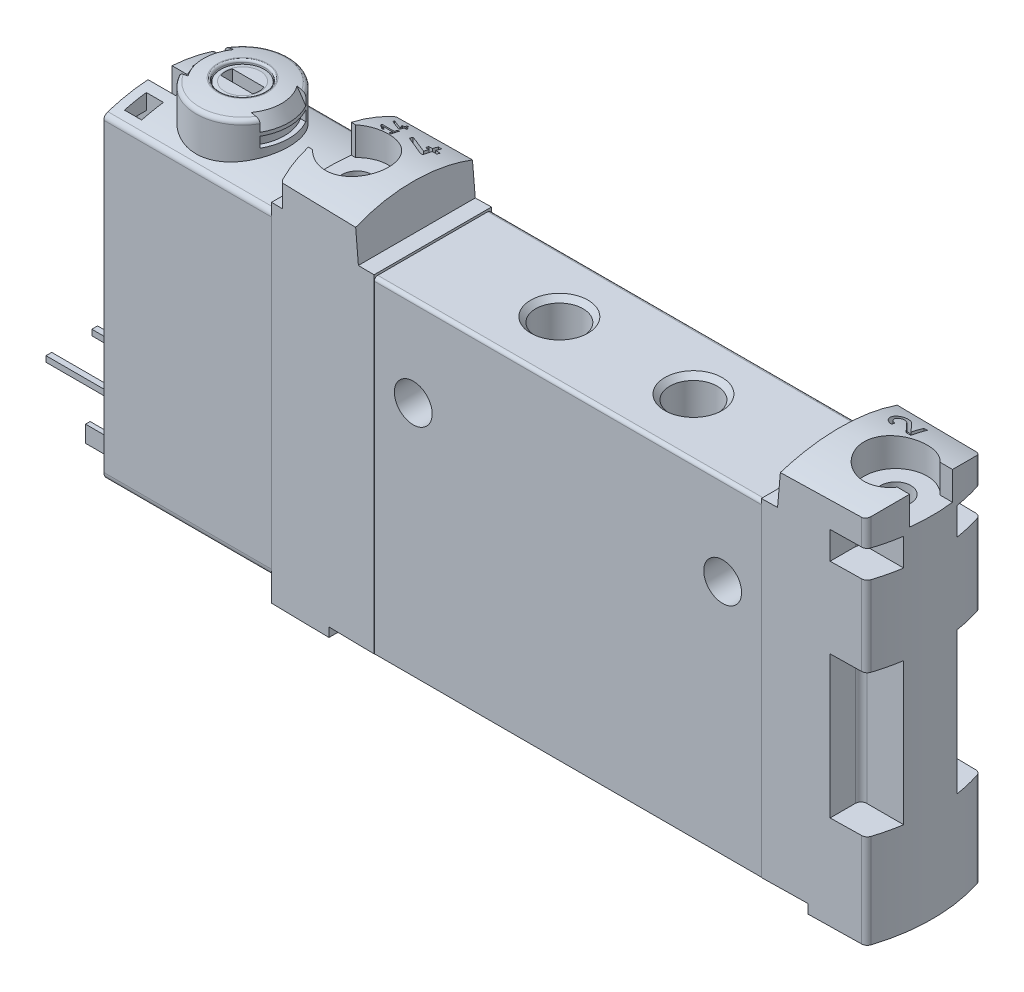
from build123d import *

# Parameters (mm, degrees)
BOSS_EXTRUDE1_DEPTH      = 16.9
BOSS_EXTRUDE1_DEPTH_BACK = 16.9
CUT_EXTRUDE1_DEPTH       = 6
CUT_EXTRUDE1_DEPTH_BACK  = 6
SKETCH2_R                = 1.65
CUT_EXTRUDE2_DEPTH       = 6
CUT_EXTRUDE2_DEPTH_BACK  = 6
SKETCH3_R                = 1.65
HOLE1_D                  = 4.134
HOLE1_DEPTH              = 13.5
HOLE1_CSINK_D            = 5
HOLE1_CSINK_ANGLE        = 90
HOLE2_D                  = 4.134
HOLE2_DEPTH              = 18.8
HOLE2_CSINK_D            = 5
HOLE2_CSINK_ANGLE        = 90
HOLE2_TIP                = 1.193383006
HOLE3_D                  = 4.134
HOLE3_DEPTH              = 13.5
HOLE3_CSINK_D            = 5
HOLE3_CSINK_ANGLE        = 90
HOLE4_D                  = 4.134
HOLE4_DEPTH              = 6.6
HOLE4_CSINK_D            = 5
HOLE4_CSINK_ANGLE        = 90
HOLE5_D                  = 4.134
HOLE5_DEPTH              = 6.6
HOLE5_CSINK_D            = 5
HOLE5_CSINK_ANGLE        = 90
HOLE6_D                  = 2.5
HOLE6_DEPTH              = 1.5
HOLE6_TIP                = 0.721687836
BOSS_EXTRUDE2_DEPTH      = 33.1
CUT_EXTRUDE3_DEPTH       = 12.4
CUT_EXTRUDE4_DEPTH       = 2.4
CUT_EXTRUDE5_DEPTH       = 6
CUT_EXTRUDE5_DEPTH_BACK  = 6
CUT_EXTRUDE6_DEPTH       = 4
BOSS_EXTRUDE3_DEPTH      = 33.1
CUT_EXTRUDE7_DEPTH       = 32
CUT_EXTRUDE7_DEPTH_BACK  = 32
CUT_EXTRUDE8_DEPTH       = 4
CUT_EXTRUDE9_DEPTH       = 6
CUT_EXTRUDE9_DEPTH_BACK  = 6
CUT_EXTRUDE10_DEPTH      = 5
CUT_EXTRUDE11_DEPTH      = 8
CUT_EXTRUDE11_DEPTH_BACK = 8
SKETCH27_W               = 41.8
SKETCH27_H               = 2
BOSS_EXTRUDE4_DEPTH      = 21.34
SKETCH29_W               = 9.8
SKETCH29_H               = 30
CUT_EXTRUDE12_DEPTH      = 6
BOSS_EXTRUDE5_DEPTH      = 1.2
BOSS_EXTRUDE5_DEPTH_BACK = 1.2
SKETCH31_W               = 6.3
SKETCH31_H               = 11
BOSS_EXTRUDE6_DEPTH      = 1
SKETCH32_W               = 0.5
SKETCH32_H               = 0.5
BOSS_EXTRUDE7_DEPTH      = 7.7
SKETCH33_W               = 0.5
SKETCH33_H               = 0.5
BOSS_EXTRUDE8_DEPTH      = 7.7
SKETCH36_W               = 4.05
SKETCH36_H               = 5.3
SKETCH37_R               = 6
CUT_EXTRUDE13_DEPTH      = 3
CUT_EXTRUDE14_DEPTH      = 2.15
CUT_EXTRUDE15_DEPTH      = 1.05
CUT_EXTRUDE15_DEPTH_BACK = 1.05
CUT_EXTRUDE16_DEPTH      = 1.5
SKETCH44_W               = 1.9
SKETCH44_H               = 3
CUT_EXTRUDE17_DEPTH      = 3
SKETCH45_W               = 1.9
SKETCH45_H               = 3
CUT_EXTRUDE18_DEPTH      = 3
CUT_EXTRUDE19_DEPTH      = 1
CUT_EXTRUDE19_DEPTH_BACK = 1
CUT_EXTRUDE20_DEPTH      = 1
CUT_EXTRUDE20_DEPTH_BACK = 1
CUT_EXTRUDE21_DEPTH      = 1
CUT_EXTRUDE21_DEPTH_BACK = 1
CUT_EXTRUDE22_DEPTH      = 1
CUT_EXTRUDE22_DEPTH_BACK = 1


with BuildPart() as part:
    # Sketch1 → Boss-Extrude1 (new, two sides: drawn at the far end of the back side and taken through both)
    with BuildSketch(Plane(origin=(0, 0, 0), x_dir=(0, 0, -1), z_dir=(1, 0, 0)).offset(-BOSS_EXTRUDE1_DEPTH_BACK)):
        with BuildLine():
            Line((-5.1, 28.15), (-5.1, 0))
            Line((-5.1, 0), (5.1, 0))
            Line((5.1, 0), (5.1, 28.15))
            ThreePointArc((5.1, 28.15), (5.012132034, 28.362132034), (4.8, 28.45))
            Line((4.8, 28.45), (-4.8, 28.45))
            ThreePointArc((-4.8, 28.45), (-5.012132034, 28.362132034), (-5.1, 28.15))
        make_face()
    extrude(amount=BOSS_EXTRUDE1_DEPTH + BOSS_EXTRUDE1_DEPTH_BACK)

    # Sketch2 → Cut-Extrude1 (cut, two sides: drawn at the far end of the back side and taken through both)
    with BuildSketch(Plane.XY.offset(-CUT_EXTRUDE1_DEPTH_BACK)):
        with Locations((-13.5, 20.65)):
            Circle(SKETCH2_R)
    extrude(amount=CUT_EXTRUDE1_DEPTH + CUT_EXTRUDE1_DEPTH_BACK, mode=Mode.SUBTRACT)

    # Sketch3 → Cut-Extrude2 (cut, two sides: drawn at the far end of the back side and taken through both)
    with BuildSketch(Plane.XY.offset(-CUT_EXTRUDE2_DEPTH_BACK)):
        with Locations((13.5, 20.65)):
            Circle(SKETCH3_R)
    extrude(amount=CUT_EXTRUDE2_DEPTH + CUT_EXTRUDE2_DEPTH_BACK, mode=Mode.SUBTRACT)

    # Hole1
    with Locations(Plane(origin=(0, 0, 0), x_dir=(-1, 0, 0), z_dir=(0, -1, 0))):
        with Locations((-11, 0)):
            CounterSinkHole(HOLE1_D / 2, HOLE1_CSINK_D / 2, depth=HOLE1_DEPTH, counter_sink_angle=HOLE1_CSINK_ANGLE)

    # Hole2
    with Locations(Plane(origin=(0, 0, 0), x_dir=(-1, 0, 0), z_dir=(0, -1, 0))):
        with Locations((0, 0)):
            CounterSinkHole(HOLE2_D / 2, HOLE2_CSINK_D / 2, depth=HOLE2_DEPTH, counter_sink_angle=HOLE2_CSINK_ANGLE)
            with Locations((0, 0, -(HOLE2_DEPTH + HOLE2_TIP / 2))):  # 120° drill point
                Cone(0, HOLE2_D / 2, HOLE2_TIP, mode=Mode.SUBTRACT)

    # Hole3
    with Locations(Plane(origin=(0, 0, 0), x_dir=(-1, 0, 0), z_dir=(0, -1, 0))):
        with Locations((11, 0)):
            CounterSinkHole(HOLE3_D / 2, HOLE3_CSINK_D / 2, depth=HOLE3_DEPTH, counter_sink_angle=HOLE3_CSINK_ANGLE)

    # Hole4
    with Locations(Plane(origin=(0, 28.45, 0), x_dir=(1, 0, 0), z_dir=(0, 1, 0))):
        with Locations((-5.85, 0)):
            CounterSinkHole(HOLE4_D / 2, HOLE4_CSINK_D / 2, depth=HOLE4_DEPTH, counter_sink_angle=HOLE4_CSINK_ANGLE)

    # Hole5
    with Locations(Plane(origin=(0, 28.45, 0), x_dir=(1, 0, 0), z_dir=(0, 1, 0))):
        with Locations((5.85, 0)):
            CounterSinkHole(HOLE5_D / 2, HOLE5_CSINK_D / 2, depth=HOLE5_DEPTH, counter_sink_angle=HOLE5_CSINK_ANGLE)

    # Hole6
    with Locations(Plane(origin=(0, 0, 0), x_dir=(-1, 0, 0), z_dir=(0, -1, 0))):
        with Locations((4.9, 3)):
            Hole(HOLE6_D / 2, depth=HOLE6_DEPTH)
            with Locations((0, 0, -(HOLE6_DEPTH + HOLE6_TIP / 2))):  # 120° drill point
                Cone(0, HOLE6_D / 2, HOLE6_TIP, mode=Mode.SUBTRACT)

    # Sketch16 → Boss-Extrude2 (add)
    with BuildSketch(Plane(origin=(0, -0.8, 0), x_dir=(1, 0, 0), z_dir=(0, 1, 0))):
        with BuildLine():
            Line((16.9, 5.125), (16.9, -5.125))
            Line((16.9, -5.125), (25.508584657, -4.974736596))
            ThreePointArc((25.508584657, -4.974736596), (25.798023023, -4.876182764), (25.975962837, -4.627536733))
            ThreePointArc((25.975962837, -4.627536733), (26.7, 0), (25.975962837, 4.627536733))
            ThreePointArc((25.975962837, 4.627536733), (25.798023023, 4.876182764), (25.508584657, 4.974736596))
            Line((25.508584657, 4.974736596), (16.9, 5.125))
        make_face()
    extrude(amount=BOSS_EXTRUDE2_DEPTH)

    # Sketch17 → Cut-Extrude3 (cut)
    with BuildSketch(Plane(origin=(0, 7.4, 0), x_dir=(1, 0, 0), z_dir=(0, 1, 0))):
        with BuildLine():
            Line((23.3, 2.325), (27.8, 2.325))
            Line((27.8, 2.325), (27.8, -2.325))
            Line((27.8, -2.325), (23.3, -2.325))
            ThreePointArc((23.3, -2.325), (22.946446609, -2.471446609), (22.8, -2.825))
            Line((22.8, -2.825), (22.8, -5.125))
            Line((22.8, -5.125), (29.8, -5.125))
            Line((29.8, -5.125), (29.8, 5.125))
            Line((29.8, 5.125), (22.8, 5.125))
            Line((22.8, 5.125), (22.8, 2.825))
            ThreePointArc((22.8, 2.825), (22.946446609, 2.471446609), (23.3, 2.325))
        make_face()
    extrude(amount=CUT_EXTRUDE3_DEPTH, mode=Mode.SUBTRACT)

    # Sketch18 → Cut-Extrude4 (cut)
    with BuildSketch(Plane(origin=(0, 26.8, 0), x_dir=(1, 0, 0), z_dir=(0, 1, 0))):
        with BuildLine():
            Line((23.3, 2.325), (27.8, 2.325))
            Line((27.8, 2.325), (27.8, -2.325))
            Line((27.8, -2.325), (23.3, -2.325))
            ThreePointArc((23.3, -2.325), (22.946446609, -2.471446609), (22.8, -2.825))
            Line((22.8, -2.825), (22.8, -5.125))
            Line((22.8, -5.125), (29.8, -5.125))
            Line((29.8, -5.125), (29.8, 5.125))
            Line((29.8, 5.125), (22.8, 5.125))
            Line((22.8, 5.125), (22.8, 2.825))
            ThreePointArc((22.8, 2.825), (22.946446609, 2.471446609), (23.3, 2.325))
        make_face()
    extrude(amount=CUT_EXTRUDE4_DEPTH, mode=Mode.SUBTRACT)

    # Sketch20 → Cut-Extrude5 (cut, two sides: drawn at the far end of the back side and taken through both)
    with BuildSketch(Plane.XY.offset(-CUT_EXTRUDE5_DEPTH_BACK)):
        Polygon((13.29, 34.65), (13.29, 28.65), (18.29, 28.65), (18.814931981, 34.65), align=None)
    extrude(amount=CUT_EXTRUDE5_DEPTH + CUT_EXTRUDE5_DEPTH_BACK, mode=Mode.SUBTRACT)

    # Sketch21 → Cut-Revolve1 (revolve, cut)
    with BuildSketch(Plane.XY):
        Polygon((23.5, 29.7), (24.825, 29.7), (24.625, -0.8), (23.5, -0.8), align=None)
    revolve(axis=Axis((23.5, -0.8, 0), (0, 1, 0)), mode=Mode.SUBTRACT)

    # Sketch22 → Cut-Extrude6 (cut)
    with BuildSketch(Plane(origin=(0, 29.7, 0), x_dir=(1, 0, 0), z_dir=(0, 1, 0))):
        with BuildLine():
            Line((25.511684617, -1.875), (28.5, -1.875))
            Line((28.5, -1.875), (28.5, 1.875))
            Line((28.5, 1.875), (25.511684617, 1.875))
            ThreePointArc((25.511684617, 1.875), (20.75, 0), (25.511684617, -1.875))
        make_face()
    extrude(amount=CUT_EXTRUDE6_DEPTH, mode=Mode.SUBTRACT)

    # Sketch23 → Boss-Extrude3 (add)
    with BuildSketch(Plane(origin=(0, -0.8, 0), x_dir=(1, 0, 0), z_dir=(0, 1, 0))):
        Polygon((-26, -4.966158909), (-16.9, -5.125), (-16.9, 5.125), (-26, 4.966158909), align=None)
    extrude(amount=BOSS_EXTRUDE3_DEPTH)

    # Sketch19 → Cut-Extrude7 (cut, two sides: drawn at the far end of the back side and taken through both)
    with BuildSketch(Plane(origin=(0, 0, 0), x_dir=(0, 0, -1), z_dir=(1, 0, 0)).offset(-CUT_EXTRUDE7_DEPTH_BACK)):
        with BuildLine():
            Line((5.125, 31.397318007), (5.125, 37))
            Line((5.125, 37), (-5.125, 37))
            Line((-5.125, 37), (-5.125, 31.397318007))
            ThreePointArc((-5.125, 31.397318007), (0, 32.3), (5.125, 31.397318007))
        make_face()
    extrude(amount=CUT_EXTRUDE7_DEPTH + CUT_EXTRUDE7_DEPTH_BACK, mode=Mode.SUBTRACT)

    # Sketch24 → Cut-Extrude8 (cut)
    with BuildSketch(Plane(origin=(0, 29.7, 0), x_dir=(1, 0, 0), z_dir=(0, 1, 0))):
        with BuildLine():
            Line((-26.5, -1.875), (-25.511684617, -1.875))
            ThreePointArc((-25.511684617, -1.875), (-20.75, 0), (-25.511684617, 1.875))
            Line((-25.511684617, 1.875), (-26.5, 1.875))
            Line((-26.5, 1.875), (-26.5, -1.875))
        make_face()
    extrude(amount=CUT_EXTRUDE8_DEPTH, mode=Mode.SUBTRACT)

    # Sketch25 → Cut-Extrude9 (cut, two sides: drawn at the far end of the back side and taken through both)
    with BuildSketch(Plane.XY.offset(-CUT_EXTRUDE9_DEPTH_BACK)):
        Polygon((-18.814931981, 34.65), (-18.29, 28.65), (-13.29, 28.65), (-13.29, 34.65), align=None)
    extrude(amount=CUT_EXTRUDE9_DEPTH + CUT_EXTRUDE9_DEPTH_BACK, mode=Mode.SUBTRACT)

    # Sketch26 → Cut-Extrude10 (cut)
    with BuildSketch(Plane(origin=(0, 29.5, 0), x_dir=(1, 0, 0), z_dir=(0, 1, 0))):
        with BuildLine():
            Line((-31.04, -6.125), (-21.04, -6.125))
            Line((-21.04, -6.125), (-21.04, -5.125))
            Line((-21.04, -5.125), (-24.773070492, -5.059839012))
            ThreePointArc((-24.773070492, -5.059839012), (-25.060599657, -4.962696441), (-25.23897685, -4.717153619))
            ThreePointArc((-25.23897685, -4.717153619), (-26, 0), (-25.23897685, 4.717153619))
            ThreePointArc((-25.23897685, 4.717153619), (-25.060599657, 4.962696441), (-24.773070492, 5.059839012))
            Line((-24.773070492, 5.059839012), (-21.04, 5.125))
            Line((-21.04, 5.125), (-21.04, 6.125))
            Line((-21.04, 6.125), (-31.04, 6.125))
            Line((-31.04, 6.125), (-31.04, -6.125))
        make_face()
    extrude(amount=CUT_EXTRUDE10_DEPTH, mode=Mode.SUBTRACT)

    # Sketch27 → Cut-Extrude11 (cut, two sides: drawn at the far end of the back side and taken through both)
    with BuildSketch(Plane.XY.offset(-CUT_EXTRUDE11_DEPTH_BACK)):
        with Locations((0, -1)):
            Rectangle(SKETCH27_W, SKETCH27_H)
    extrude(amount=CUT_EXTRUDE11_DEPTH + CUT_EXTRUDE11_DEPTH_BACK, mode=Mode.SUBTRACT)

    # Sketch28 → Boss-Extrude4 (add)
    with BuildSketch(Plane(origin=(-21.86, 0, 0), x_dir=(0, 0, -1), z_dir=(1, 0, 0))):
        with BuildLine():
            Line((-4.2, 1), (4.2, 1))
            ThreePointArc((4.2, 1), (4.694974747, 1.205025253), (4.9, 1.7))
            Line((4.9, 1.7), (4.9, 28.316294728))
            ThreePointArc((4.9, 28.316294728), (4.803647166, 28.611369236), (4.551724138, 28.792718684))
            ThreePointArc((4.551724138, 28.792718684), (0, 29.5), (-4.551724138, 28.792718684))
            ThreePointArc((-4.551724138, 28.792718684), (-4.803647166, 28.611369236), (-4.9, 28.316294728))
            Line((-4.9, 28.316294728), (-4.9, 1.7))
            ThreePointArc((-4.9, 1.7), (-4.694974747, 1.205025253), (-4.2, 1))
        make_face()
    extrude(amount=-BOSS_EXTRUDE4_DEPTH)

    # Sketch29 → Cut-Extrude12 (cut)
    with BuildSketch(Plane(origin=(-40.7, 0, 0), x_dir=(0, 0, -1), z_dir=(1, 0, 0))):
        with Locations((0, 16)):
            Rectangle(SKETCH29_W, SKETCH29_H)
        with BuildLine():
            Line((-4, 2.2), (-3.55, 1.75))
            Line((-3.55, 1.75), (3.55, 1.75))
            Line((3.55, 1.75), (4, 2.2))
            Line((4, 2.2), (4, 3.65))
            Line((4, 3.65), (3.6, 3.65))
            Line((3.6, 3.65), (3.6, 2.95))
            ThreePointArc((3.6, 2.95), (3.453553391, 2.596446609), (3.1, 2.45))
            Line((3.1, 2.45), (-3.1, 2.45))
            ThreePointArc((-3.1, 2.45), (-3.453553391, 2.596446609), (-3.6, 2.95))
            Line((-3.6, 2.95), (-3.6, 3.65))
            Line((-3.6, 3.65), (-4, 3.65))
            Line((-4, 3.65), (-4, 2.2))
        make_face(mode=Mode.SUBTRACT)
    extrude(amount=-CUT_EXTRUDE12_DEPTH, mode=Mode.SUBTRACT)

    # Sketch30 → Boss-Extrude5 (add, two sides: drawn at the far end of the back side and taken through both)
    with BuildSketch(Plane.XY.offset(-BOSS_EXTRUDE5_DEPTH_BACK)):
        Polygon((-43.2, 1.75), (-42.12774654, 1.25), (-41.9, 1.25), (-41.9, 1.75), align=None)
    extrude(amount=BOSS_EXTRUDE5_DEPTH + BOSS_EXTRUDE5_DEPTH_BACK)

    # Sketch31 → Boss-Extrude6 (add)
    with BuildSketch(Plane(origin=(-40.7, 0, 0), x_dir=(0, 0, -1), z_dir=(1, 0, 0))):
        with Locations((0, 8.6)):
            Rectangle(SKETCH31_W, SKETCH31_H)
    extrude(amount=-BOSS_EXTRUDE6_DEPTH)

    # Sketch32 → Boss-Extrude7 (add)
    with BuildSketch(Plane(origin=(-40.7, 0, 0), x_dir=(0, 0, -1), z_dir=(1, 0, 0))):
        with Locations((-2, 5.1)):
            Rectangle(SKETCH32_W, SKETCH32_H)
    extrude(amount=-BOSS_EXTRUDE7_DEPTH)

    # Sketch33 → Boss-Extrude8 (add)
    with BuildSketch(Plane(origin=(-40.7, 0, 0), x_dir=(0, 0, -1), z_dir=(1, 0, 0))):
        with Locations((2, 5.1)):
            Rectangle(SKETCH33_W, SKETCH33_H)
    extrude(amount=-BOSS_EXTRUDE8_DEPTH)

    # Sketch34 → Hole7 (revolve, cut)
    with BuildSketch(Plane(origin=(-23.5, 29.7, 0), x_dir=(0, 0, 1), z_dir=(1, 0, 0))):
        Polygon((0, 0), (0, 30.5), (1.125, 30.5), (1.325, 0), align=None)
    revolve(axis=Axis((-23.5, -80.3, 0), (0, 1, 0)), mode=Mode.SUBTRACT)

    # Sketch36 → Revolve1 (revolve)
    with BuildSketch(Plane.XY):
        with Locations((-31.475, 30.015)):
            Rectangle(SKETCH36_W, SKETCH36_H)
    revolve(axis=Axis((-33.5, 27.365, 0), (0, 1, 0)))

    # Sketch37 → Cut-Extrude13 (cut)
    with BuildSketch(Plane(origin=(0, 30.1, 0), x_dir=(1, 0, 0), z_dir=(0, 1, 0))):
        with Locations((-33.5, 0)):
            Circle(SKETCH37_R)
        with BuildLine():
            Line((-28.917424305, -2), (-30.750454583, -2))
            ThreePointArc((-30.750454583, -2), (-30.1, 0), (-30.750454583, 2))
            Line((-30.750454583, 2), (-28.917424305, 2))
            ThreePointArc((-28.917424305, 2), (-33.5, 5), (-38.082575695, 2))
            Line((-38.082575695, 2), (-36.249545417, 2))
            ThreePointArc((-36.249545417, 2), (-36.9, 0), (-36.249545417, -2))
            Line((-36.249545417, -2), (-38.082575695, -2))
            ThreePointArc((-38.082575695, -2), (-33.5, -5), (-28.917424305, -2))
        make_face(mode=Mode.SUBTRACT)
    extrude(amount=CUT_EXTRUDE13_DEPTH, mode=Mode.SUBTRACT)

    # Sketch38 → Revolve2 (revolve)
    with BuildSketch(Plane.XY):
        Polygon((-30.1, 32.440833025), (-30.1, 27.365), (-29.45, 27.365), (-29.45, 30.115), (-29.85, 30.115), (-29.85, 31.015), (-29.45, 31.015), (-29.45, 31.315), align=None)
    revolve(axis=Axis((-33.5, 27.365, 0), (0, 1, 0)))

    # Sketch39 → Cut-Revolve2 (revolve, cut)
    with BuildSketch(Plane.XY):
        with BuildLine():
            Line((-33.5, 33.365), (-28.5, 33.365))
            Line((-28.5, 33.365), (-28.5, 29.865))
            Line((-28.5, 29.865), (-29.45, 29.865))
            Line((-29.45, 29.865), (-29.45, 31.961389214))
            ThreePointArc((-29.45, 31.961389214), (-29.533772234, 32.206338188), (-29.75, 32.348687548))
            ThreePointArc((-29.75, 32.348687548), (-30.531233711, 32.528279455), (-31.320945946, 32.665880143))
            ThreePointArc((-31.320945946, 32.665880143), (-31.480746299, 32.61934706), (-31.55, 32.468001741))
            Line((-31.55, 32.468001741), (-31.55, 31.295))
            Line((-31.55, 31.295), (-33.5, 31.295))
            Line((-33.5, 31.295), (-33.5, 33.365))
        make_face()
    revolve(axis=Axis((-33.5, 31.295, 0), (0, 1, 0)), mode=Mode.SUBTRACT)

    # Sketch40 → Revolve3 (revolve)
    with BuildSketch(Plane.XY):
        with BuildLine():
            Line((-33.5, 32.41), (-31.955768486, 32.41))
            Line((-31.955768486, 32.41), (-31.6, 32.36))
            Line((-31.6, 32.36), (-31.6, 30.71))
            ThreePointArc((-31.6, 30.71), (-31.453553391, 30.356446609), (-31.1, 30.21))
            Line((-31.1, 30.21), (-30.95, 30.21))
            Line((-30.95, 30.21), (-30.95, 26.41))
            Line((-30.95, 26.41), (-33.5, 26.41))
            Line((-33.5, 26.41), (-33.5, 32.41))
        make_face()
    revolve(axis=Axis((-33.5, 26.41, 0), (0, 1, 0)))

    # Sketch41 → Cut-Extrude14 (cut)
    with BuildSketch(Plane(origin=(0, 32.41, 0), x_dir=(1, 0, 0), z_dir=(0, 1, 0))):
        with BuildLine():
            Line((-34.892982412, -0.5), (-32.107017588, -0.5))
            ThreePointArc((-32.107017588, -0.5), (-32.02, 0), (-32.107017588, 0.5))
            Line((-32.107017588, 0.5), (-34.892982412, 0.5))
            ThreePointArc((-34.892982412, 0.5), (-34.98, 0), (-34.892982412, -0.5))
        make_face()
    extrude(amount=-CUT_EXTRUDE14_DEPTH, mode=Mode.SUBTRACT)

    # Sketch42 → Cut-Extrude15 (cut, two sides: drawn at the far end of the back side and taken through both)
    with BuildSketch(Plane.XY.offset(-CUT_EXTRUDE15_DEPTH_BACK)):
        Polygon((-45.796, 29.534), (-45.796, 18.480752766), (-38.296, 24.774), (-38.296, 29.534), align=None)
    extrude(amount=CUT_EXTRUDE15_DEPTH + CUT_EXTRUDE15_DEPTH_BACK, mode=Mode.SUBTRACT)

    # Sketch43 → Cut-Extrude16 (cut)
    with BuildSketch(Plane(origin=(-38.4, 0, 0), x_dir=(0, 0, -1), z_dir=(1, 0, 0))):
        Polygon((-3.9, 31), (-3.9, 25), (-2, 25), (-2, 30), (2, 30), (2, 25), (3.9, 25), (3.9, 31), align=None)
    extrude(amount=-CUT_EXTRUDE16_DEPTH, mode=Mode.SUBTRACT)

    # Sketch44 → Cut-Extrude17 (cut)
    with BuildSketch(Plane(origin=(-38.4, 0, 0), x_dir=(0, 0, -1), z_dir=(1, 0, 0))):
        with Locations((-2.95, 26.5)):
            Rectangle(SKETCH44_W, SKETCH44_H)
    extrude(amount=-CUT_EXTRUDE17_DEPTH, mode=Mode.SUBTRACT)

    # Sketch45 → Cut-Extrude18 (cut)
    with BuildSketch(Plane(origin=(-38.4, 0, 0), x_dir=(0, 0, -1), z_dir=(1, 0, 0))):
        with Locations((2.95, 26.5)):
            Rectangle(SKETCH45_W, SKETCH45_H)
    extrude(amount=-CUT_EXTRUDE18_DEPTH, mode=Mode.SUBTRACT)

    # Sketch46 → Cut-Extrude19 (cut, two sides: drawn at the far end of the back side and taken through both)
    with BuildSketch(Plane(origin=(0, 31.7, 0), x_dir=(1, 0, 0), z_dir=(0, 1, 0)).offset(-CUT_EXTRUDE19_DEPTH_BACK)):
        Polygon((-24.64, 3.175), (-24.178028118, 2.851523806), (-24.107551171, 2.952175316), (-24.425777799, 3.175), (-23.59, 3.175), (-23.59, 2.875), (-23.44, 2.875), (-23.44, 3.625), (-23.59, 3.625), (-23.59, 3.325), (-24.64, 3.325), align=None)
    extrude(amount=CUT_EXTRUDE19_DEPTH + CUT_EXTRUDE19_DEPTH_BACK, mode=Mode.SUBTRACT)

    # Sketch47 → Cut-Extrude20 (cut, two sides: drawn at the far end of the back side and taken through both)
    with BuildSketch(Plane(origin=(0, 31.7, 0), x_dir=(1, 0, 0), z_dir=(0, 1, 0)).offset(-CUT_EXTRUDE20_DEPTH_BACK)):
        Polygon((-24.64, 4.25080097), (-23.748311942, 3.835), (-23.64, 3.835), (-23.64, 4.25), (-23.44, 4.25), (-23.44, 4.4), (-23.64, 4.4), (-23.64, 4.665), (-23.79, 4.665), (-23.79, 4.4), (-23.94, 4.4), (-23.94, 4.25), (-23.79, 4.25), (-23.79, 4.019946149), (-24.64, 4.416307658), align=None)
    extrude(amount=CUT_EXTRUDE20_DEPTH + CUT_EXTRUDE20_DEPTH_BACK, mode=Mode.SUBTRACT)

    # Sketch48 → Cut-Extrude21 (cut, two sides: drawn at the far end of the back side and taken through both)
    with BuildSketch(Plane(origin=(0, 31.7, 0), x_dir=(1, 0, 0), z_dir=(0, 1, 0)).offset(-CUT_EXTRUDE21_DEPTH_BACK)):
        Polygon((-22.44, 3.501601941), (-20.656623883, 2.67), (-20.44, 2.67), (-20.44, 3.5), (-20.04, 3.5), (-20.04, 3.8), (-20.44, 3.8), (-20.44, 4.33), (-20.74, 4.33), (-20.74, 3.8), (-21.04, 3.8), (-21.04, 3.5), (-20.74, 3.5), (-20.74, 3.039892297), (-22.44, 3.832615316), align=None)
    extrude(amount=CUT_EXTRUDE21_DEPTH + CUT_EXTRUDE21_DEPTH_BACK, mode=Mode.SUBTRACT)

    # Sketch49 → Cut-Extrude22 (cut, two sides: drawn at the far end of the back side and taken through both)
    with BuildSketch(Plane(origin=(0, 31.7, 0), x_dir=(1, 0, 0), z_dir=(0, 1, 0)).offset(-CUT_EXTRUDE22_DEPTH_BACK)):
        with BuildLine():
            Line((20.365, 2.775), (20.365, 3.075))
            ThreePointArc((20.365, 3.075), (19.9749681, 3.668819777), (20.674859287, 3.790881801))
            Line((20.674859287, 3.790881801), (21.628522903, 2.775))
            Line((21.628522903, 2.775), (22.04, 2.775))
            Line((22.04, 2.775), (22.04, 4.225))
            Line((22.04, 4.225), (21.74, 4.225))
            Line((21.74, 4.225), (21.74, 3.094572368))
            Line((21.74, 3.094572368), (20.89358349, 3.996210131))
            ThreePointArc((20.89358349, 3.996210131), (19.699651465, 3.787986679), (20.365, 2.775))
        make_face()
    extrude(amount=CUT_EXTRUDE22_DEPTH + CUT_EXTRUDE22_DEPTH_BACK, mode=Mode.SUBTRACT)


solid = part.part
